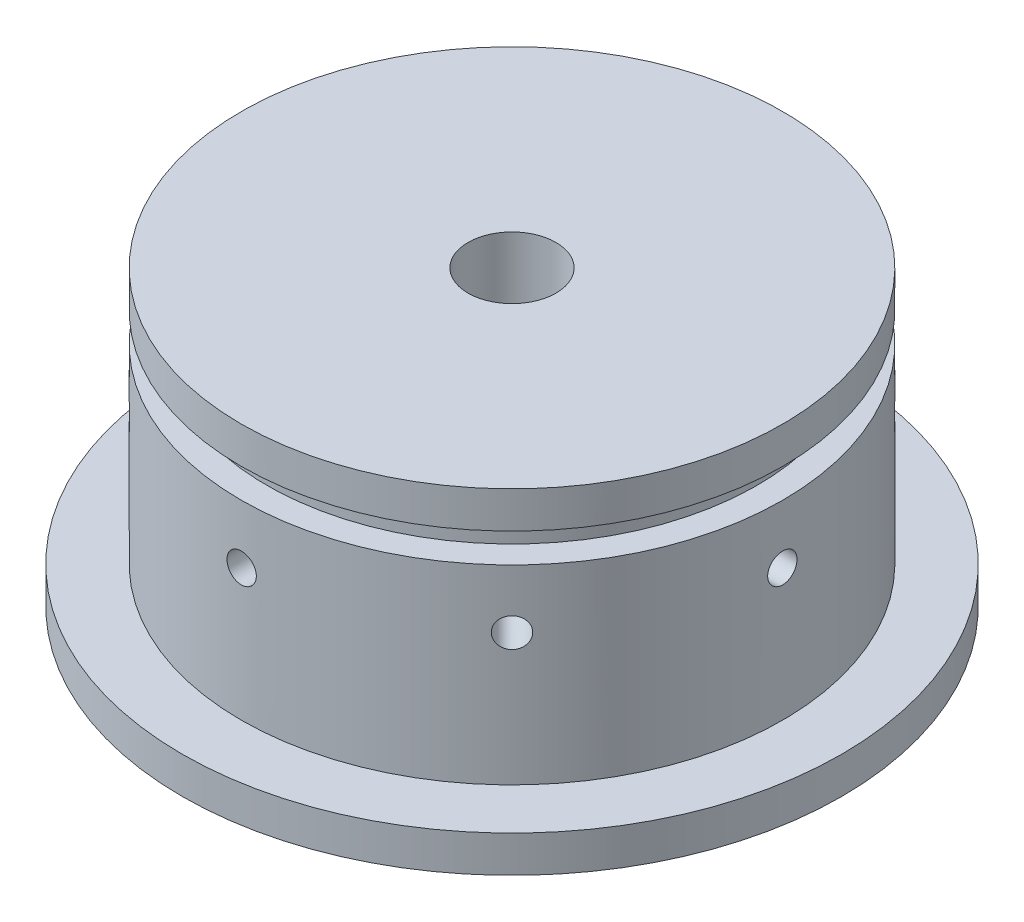
from build123d import *

# Parameters (mm, degrees)
SKETCH1_R           = 45
BOSS_EXTRUDE1_DEPTH = 40
SKETCH2_R           = 45
SKETCH2_R_2         = 36.95
CUT_EXTRUDE1_DEPTH  = 35
SKETCH5_W           = 3.5
SKETCH5_H           = 4
SKETCH6_R           = 2
CUT_EXTRUDE4_DEPTH  = 46
SKETCH8_R           = 2
BOSS_EXTRUDE2_DEPTH = 30
CIRPATTERN1_COUNT   = 8
SKETCH4_R           = 6
CUT_EXTRUDE3_DEPTH  = 77


with BuildPart() as part:
    # Sketch1 → Boss-Extrude1 (new body)
    with BuildSketch(Plane(origin=(0, 0, 0), x_dir=(1, 0, 0), z_dir=(0, 1, 0))):
        Circle(SKETCH1_R)
    extrude(amount=BOSS_EXTRUDE1_DEPTH)

    # Sketch2 → Cut-Extrude1 (cut)
    with BuildSketch(Plane(origin=(0, 40, 0), x_dir=(1, 0, 0), z_dir=(0, 1, 0))):
        Circle(SKETCH2_R)
        Circle(SKETCH2_R_2, mode=Mode.SUBTRACT)
    extrude(amount=-CUT_EXTRUDE1_DEPTH, mode=Mode.SUBTRACT)

    # Sketch5 → Cut-Revolve1 (revolve, cut)
    with BuildSketch(Plane.XY):
        with Locations((-35.2, 33)):
            Rectangle(SKETCH5_W, SKETCH5_H)
    revolve(axis=Axis((0, 0, 0), (0, 1, 0)), mode=Mode.SUBTRACT)

    # Sketch6 → Cut-Extrude4 (cut)
    with BuildSketch(Plane.XY):
        with Locations((0, 23)):
            Circle(SKETCH6_R)
    cut_extrude4 = extrude(amount=-CUT_EXTRUDE4_DEPTH, mode=Mode.SUBTRACT)

    # Sketch8 → Boss-Extrude2 (add)
    with BuildSketch(Plane(origin=(0, 0, 0), x_dir=(-1, 0, 0), z_dir=(0, 0, -1))):
        with Locations((0, 23)):
            Circle(SKETCH8_R)
    boss_extrude2 = extrude(amount=BOSS_EXTRUDE2_DEPTH)

    # CirPattern1: Cut-Extrude4, Boss-Extrude2 ×8 about axis
    cirpattern1_axis = Axis((0, 0, 0), (0, 1, 0))
    for i in range(1, CIRPATTERN1_COUNT):
        add(cut_extrude4.rotate(cirpattern1_axis, i * 360 / CIRPATTERN1_COUNT), mode=Mode.SUBTRACT)
        add(boss_extrude2.rotate(cirpattern1_axis, i * 360 / CIRPATTERN1_COUNT))

    # Sketch4 → Cut-Extrude3 (cut)
    with BuildSketch(Plane.XZ):
        Circle(SKETCH4_R)
    extrude(amount=-CUT_EXTRUDE3_DEPTH, mode=Mode.SUBTRACT)


solid = part.part
